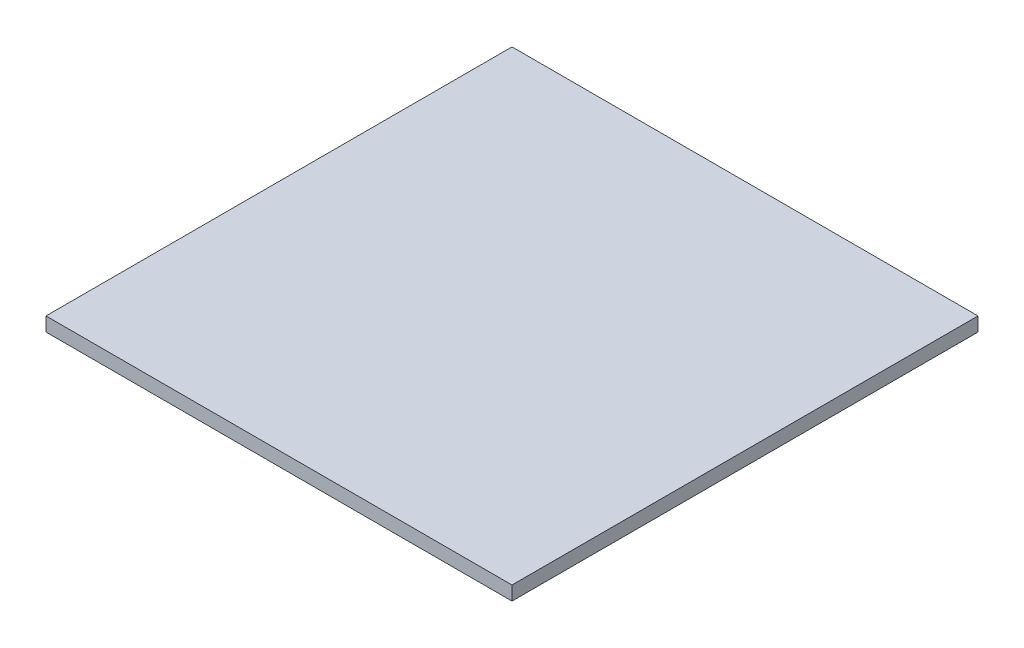
from build123d import *

# Parameters (mm, degrees)
SKETCH1_W           = 200
SKETCH1_H           = 200
BOSS_EXTRUDE1_DEPTH = 6


with BuildPart() as part:
    # Sketch1 → Boss-Extrude1 (new body)
    with BuildSketch(Plane(origin=(0, 0, 0), x_dir=(1, 0, 0), z_dir=(0, 1, 0))):
        with Locations((100, 100)):
            Rectangle(SKETCH1_W, SKETCH1_H)
    extrude(amount=BOSS_EXTRUDE1_DEPTH)


solid = part.part
